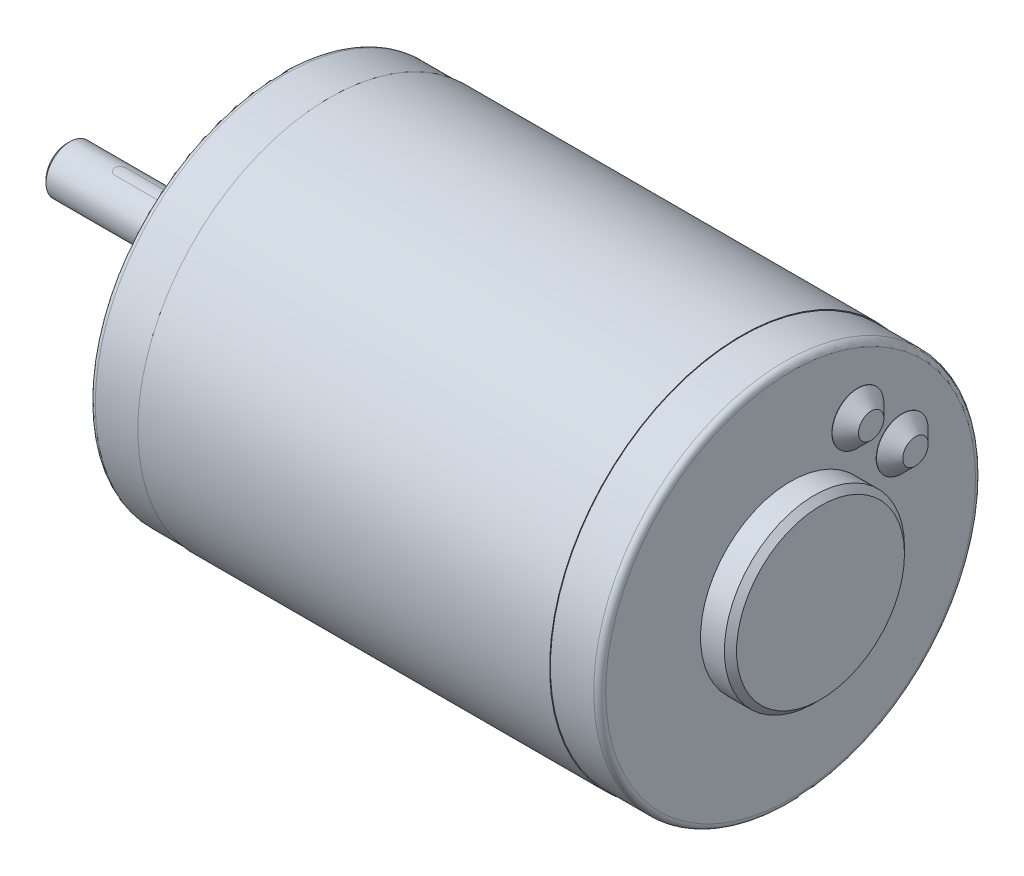
from build123d import *

# Parameters (mm, degrees)
SKETCH1_W                  = 68.7568
SKETCH1_H                  = 32.004
SKETCH2_R                  = 31.877
BOSS_EXTRUDE1_DEPTH        = 8.2296
SKETCH3_R                  = 15.0368
BOSS_EXTRUDE2_DEPTH        = 5
SKETCH4_R                  = 31.877
BOSS_EXTRUDE3_DEPTH        = 8.2296
SKETCH5_R                  = 9.525
BOSS_EXTRUDE4_DEPTH        = 4
SKETCH6_R                  = 4
BOSS_EXTRUDE5_DEPTH        = 31.6
CUT_EXTRUDE1_REACH         = 31.204
M3_5_CLEARANCE_HOLE1_D     = 4.0386
M3_5_CLEARANCE_HOLE1_DEPTH = 13.6144
M3_5_CLEARANCE_HOLE1_TIP   = 1.213317848
CHAMFER1_SIZE              = 1.016
CHAMFER2_SIZE              = 0.5
FILLET1_R                  = 1


with BuildPart() as part:
    # Sketch1 → Revolve1 (revolve)
    with BuildSketch(Plane.XY):
        with Locations((42.608, 16.002)):
            Rectangle(SKETCH1_W, SKETCH1_H)
    revolve(axis=Axis((8.2296, 0, 0), (1, 0, 0)))

    # Sketch2 → Boss-Extrude1 (add)
    with BuildSketch(Plane(origin=(76.9864, 0, 0), x_dir=(0, 0, -1), z_dir=(1, 0, 0))):
        Circle(SKETCH2_R)
    extrude(amount=BOSS_EXTRUDE1_DEPTH)

    # Sketch3 → Boss-Extrude2 (add)
    with BuildSketch(Plane(origin=(85.216, 0, 0), x_dir=(0, 0, -1), z_dir=(1, 0, 0))):
        Circle(SKETCH3_R)
    extrude(amount=BOSS_EXTRUDE2_DEPTH)

    # Sketch4 → Boss-Extrude3 (add)
    with BuildSketch(Plane.ZY.offset(-8.2296)):
        Circle(SKETCH4_R)
    extrude(amount=BOSS_EXTRUDE3_DEPTH)

    # Sketch5 → Boss-Extrude4 (add)
    with BuildSketch(Plane.ZY):
        Circle(SKETCH5_R)
    extrude(amount=BOSS_EXTRUDE4_DEPTH)

    # Sketch6 → Boss-Extrude5 (add)
    with BuildSketch(Plane.ZY.offset(4)):
        Circle(SKETCH6_R)
    extrude(amount=BOSS_EXTRUDE5_DEPTH)

    # Sketch7 → Cut-Extrude1 (cut, up to next)
    with BuildSketch(Plane.XZ.offset(-2.8), mode=Mode.PRIVATE) as cut_extrude1_sk1:
        with BuildLine():
            Line((-7.1, 1), (-26.6, 1))
            ThreePointArc((-26.6, 1), (-27.6, 0), (-26.6, -1))
            Line((-26.6, -1), (-7.1, -1))
            ThreePointArc((-7.1, -1), (-6.1, 0), (-7.1, 1))
        make_face()
    cut_extrude1_tool1 = extrude(cut_extrude1_sk1.sketch, amount=-CUT_EXTRUDE1_REACH, mode=Mode.PRIVATE) & part.part
    add(cut_extrude1_tool1.solids().sort_by_distance((-16.85, 2.8, 0))[0], mode=Mode.SUBTRACT)

    # Sketch8 → Revolve2 (revolve)
    with BuildSketch(Plane.XY.offset(-18.607090683)):
        Polygon((85.216, 15.525359639), (85.216, 11.207359639), (87.4639, 11.207359639), (87.4639, 13.325359639), (85.2639, 15.525359639), align=None)
    revolve(axis=Axis((85.216, 11.207359639, -18.607090683), (1, 0, 0)))

    # Sketch9 → Revolve3 (revolve)
    with BuildSketch(Plane.XY.offset(-11.207359639)):
        Polygon((85.216, 22.925090683), (85.216, 18.607090683), (87.4639, 18.607090683), (87.4639, 20.725090683), (85.2639, 22.925090683), align=None)
    revolve(axis=Axis((85.216, 18.607090683, -11.207359639), (1, 0, 0)))

    # M3.5 Clearance Hole1
    with Locations(Plane.ZY):
        with Locations((0, 25.4), (0, -25.4)):
            Hole(M3_5_CLEARANCE_HOLE1_D / 2, depth=M3_5_CLEARANCE_HOLE1_DEPTH)
            with Locations((0, 0, -(M3_5_CLEARANCE_HOLE1_DEPTH + M3_5_CLEARANCE_HOLE1_TIP / 2))):  # 118° drill point
                Cone(0, M3_5_CLEARANCE_HOLE1_D / 2, M3_5_CLEARANCE_HOLE1_TIP, mode=Mode.SUBTRACT)

    # Chamfer1
    chamfer1_edges = [part.edges().sort_by_distance(p)[0] for p in [
        (90.216, 0, 15.0368),
        (-4, 0, -9.525),
    ]]
    chamfer(chamfer1_edges, length=CHAMFER1_SIZE)

    # Chamfer2
    chamfer2_edges = [part.edges().sort_by_distance(p)[0] for p in [
        (-35.6, 0, -4),
    ]]
    chamfer(chamfer2_edges, length=CHAMFER2_SIZE)

    # Fillet1
    fillet1_edges = [part.edges().sort_by_distance(p)[0] for p in [
        (0, 0, -31.877),
        (85.216, 0, 31.877),
    ]]
    fillet(fillet1_edges, radius=FILLET1_R)


solid = part.part
